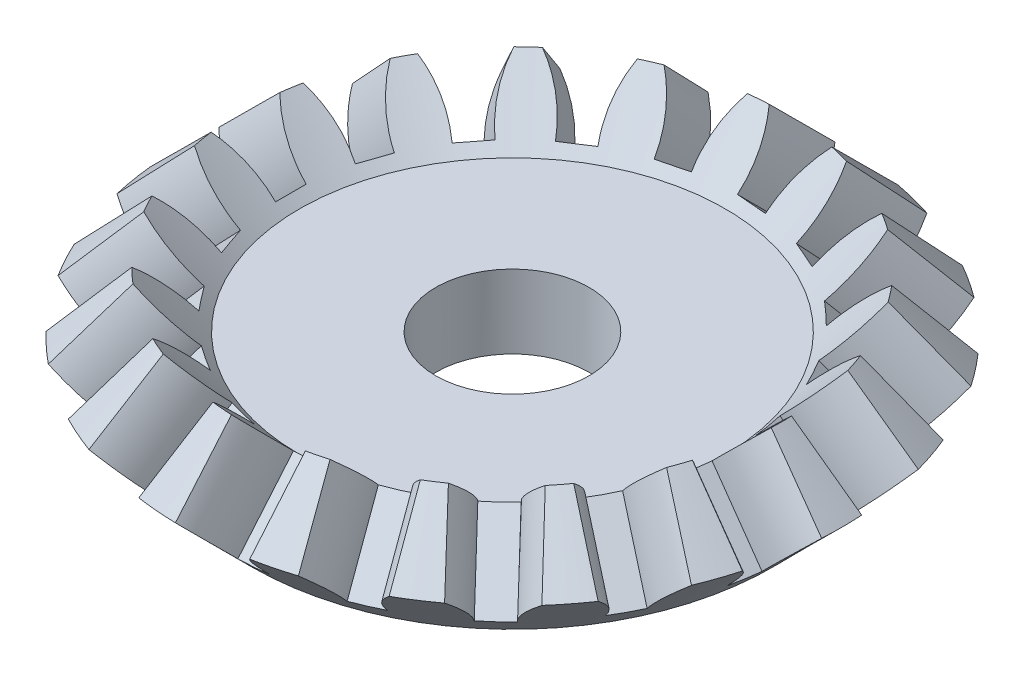
from build123d import *

# Parameters (mm, degrees)
CUT_EXTRUDE1_START = -6.621687
CUT_EXTRUDE1_DEPTH = 6.621687
CIRPATTERN3_COUNT  = 19
CUT_EXTRUDE2_REACH = 7.575
SKETCH5_R          = 5.8075


with BuildPart() as part:
    # Sketch2 → Revolve2 (revolve)
    with BuildSketch(Plane(origin=(0, 0, 0), x_dir=(0, 0, -1), z_dir=(1, 0, 0))):
        Polygon((0, 0), (-19.7455, 0), (-24.992178189, 5.246678189), (-20.392872842, 9.845983537), (-16.122089305, 5.5752), (0, 5.5752), align=None)
    revolve(axis=Axis((0, 5.5752, 0), (0, -1, 0)))

    # Sketch4 → Cut-Extrude1 (cut)
    with BuildSketch(Plane(origin=(-9.87275, -9.87275, 0), x_dir=(0, 0, 1), z_dir=(-0.707106781, -0.707106781, 0)).offset(CUT_EXTRUDE1_START)):
        with BuildLine():
            Line((-1.1615, 16.305386829), (1.1615, 16.305386829))
            ThreePointArc((1.1615, 16.305386829), (1.823938006, 19.750952646), (3.7168, 22.705241289))
            Line((3.7168, 22.705241289), (-3.7168, 22.705241289))
            ThreePointArc((-3.7168, 22.705241289), (-1.823938006, 19.750952646), (-1.1615, 16.305386829))
        make_face()
    cut_extrude1 = extrude(amount=CUT_EXTRUDE1_DEPTH, mode=Mode.SUBTRACT)

    # CirPattern3: Cut-Extrude1 ×19 about axis
    cirpattern3_axis = Axis((0, 0, 0), (0, 1, 0))
    for i in range(1, CIRPATTERN3_COUNT):
        add(cut_extrude1.rotate(cirpattern3_axis, i * 360 / CIRPATTERN3_COUNT), mode=Mode.SUBTRACT)

    # Sketch5 → Cut-Extrude2 (cut, up to next)
    with BuildSketch(Plane(origin=(0, 5.5752, 0), x_dir=(1, 0, 0), z_dir=(0, 1, 0)), mode=Mode.PRIVATE) as cut_extrude2_sk1:
        Circle(SKETCH5_R)
    cut_extrude2_tool1 = extrude(cut_extrude2_sk1.sketch, amount=-CUT_EXTRUDE2_REACH, mode=Mode.PRIVATE) & part.part
    add(cut_extrude2_tool1.solids().sort_by_distance((0, 5.5752, 0))[0], mode=Mode.SUBTRACT)


solid = part.part
